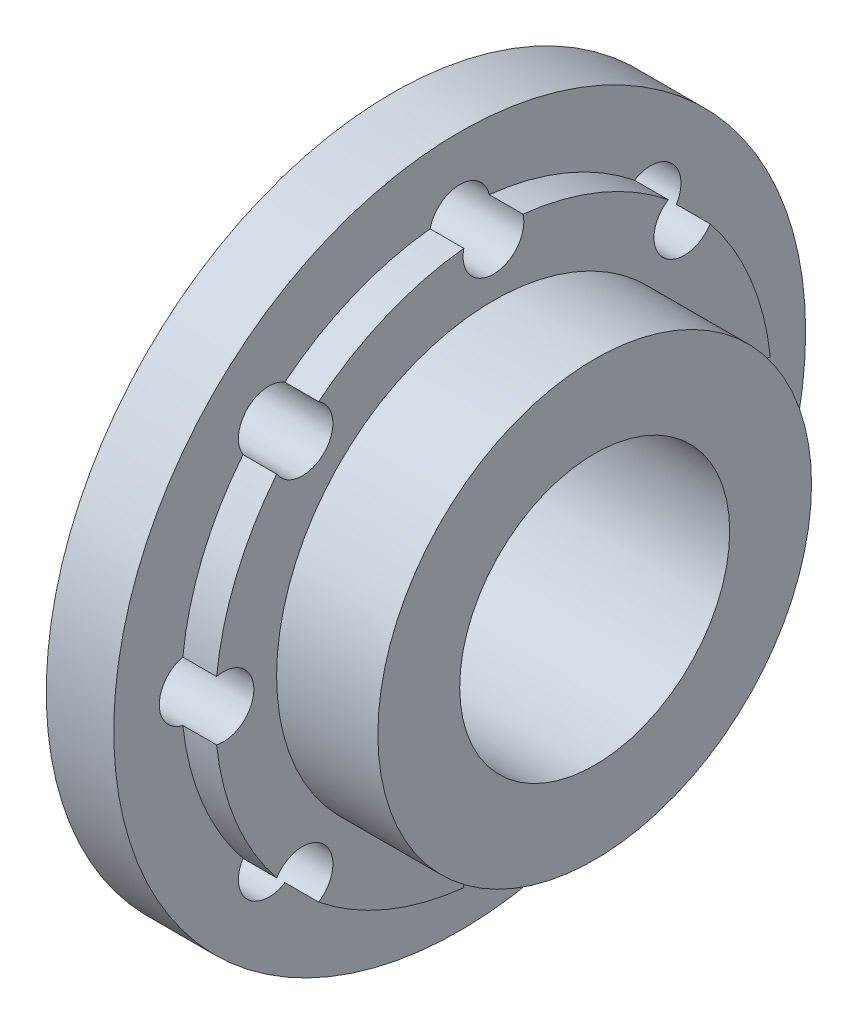
from build123d import *

# Parameters (mm, degrees)
MOVE_FACE1_BY      = 0.075
MOVE_FACE2_BY      = 0.25
SKETCH2_R          = 0.9
CUT_EXTRUDE1_DEPTH = 16.68837149


with BuildPart() as part:
    # Sketch1 → Revolve1 (revolve)
    with BuildSketch(Plane.XY, mode=Mode.PRIVATE) as revolve1_sk:
        Polygon((0, 4), (0, 6.5), (-3, 6.5), (-3, 8.5), (-4, 8.5), (-4, 10.25), (-6, 10.25), (-6, 4), align=None)
    revolve(revolve1_sk.sketch.rotate(Axis((0, 0, 0), (-1, 0, 0)), 90), axis=Axis((0, 0, 0), (-1, 0, 0)))

    # Move Face1: a curved face moved inward by 0.075
    add(Solid.thicken(part.faces().sort_by_distance((-1.5, 0, 6.5))[0], -MOVE_FACE1_BY), mode=Mode.SUBTRACT)

    # Move Face2: a curved face moved inward by 0.25
    add(Solid.thicken(part.faces().sort_by_distance((-3.5, 0, 8.5))[0], -MOVE_FACE2_BY), mode=Mode.SUBTRACT)

    # Sketch2 → Cut-Extrude1 (cut, through all)
    with BuildSketch(Plane.ZY.offset(6)):
        with Locations((0, 8)):
            Circle(SKETCH2_R)
        with Locations((5.656854249, 5.656854249)):
            Circle(SKETCH2_R)
        with Locations((8, 0)):
            Circle(SKETCH2_R)
        with Locations((5.656854249, -5.656854249)):
            Circle(SKETCH2_R)
        with Locations((0, -8)):
            Circle(SKETCH2_R)
        with Locations((-5.656854249, -5.656854249)):
            Circle(SKETCH2_R)
        with Locations((-8, 0)):
            Circle(SKETCH2_R)
        with Locations((-5.656854249, 5.656854249)):
            Circle(SKETCH2_R)
    extrude(amount=-CUT_EXTRUDE1_DEPTH, mode=Mode.SUBTRACT)


solid = part.part
